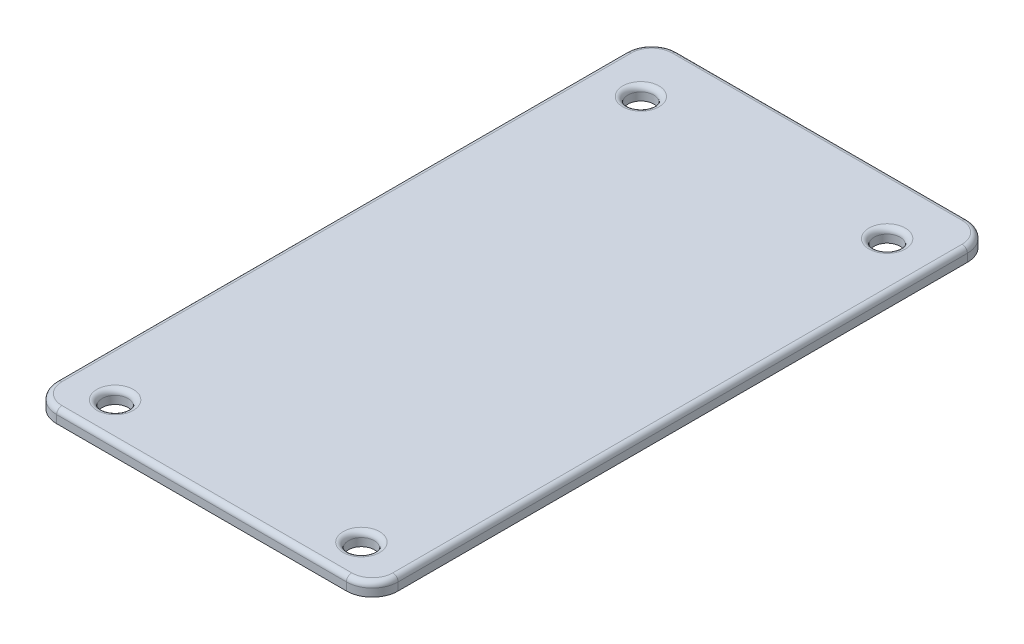
from build123d import *

# Parameters (mm, degrees)
SKETCH1_W           = 33
SKETCH1_H           = 60
BOSS_EXTRUDE1_DEPTH = 1.27
CUT_EXTRUDE1_REACH  = 3.27
SKETCH2_R           = 1.245715159
SKETCH2_R_2         = 1.25
FILLET1_R           = 2.50000008
FILLET2_R           = 0.508


with BuildPart() as part:
    # Sketch1 → Boss-Extrude1 (new body)
    with BuildSketch(Plane(origin=(0, 0, 0), x_dir=(1, 0, 0), z_dir=(0, 1, 0))):
        with Locations((16.989591658, -21.38828823)):
            Rectangle(SKETCH1_W, SKETCH1_H)
    extrude(amount=BOSS_EXTRUDE1_DEPTH)

    # Sketch2 → Cut-Extrude1 (cut, up to next)
    with BuildSketch(Plane(origin=(0, 1.27, 0), x_dir=(1, 0, 0), z_dir=(0, 1, 0)), mode=Mode.PRIVATE) as cut_extrude1_sk1:
        with Locations((5.093876499, 2.96171177)):
            Circle(SKETCH2_R)
    cut_extrude1_tool1 = extrude(cut_extrude1_sk1.sketch, amount=-CUT_EXTRUDE1_REACH, mode=Mode.PRIVATE) & part.part
    add(cut_extrude1_tool1.solids().sort_by_distance((5.093876, 1.27, -2.961712))[0], mode=Mode.SUBTRACT)
    # Sketch2 → Cut-Extrude1 (cut, up to next)
    with BuildSketch(Plane(origin=(0, 1.27, 0), x_dir=(1, 0, 0), z_dir=(0, 1, 0)), mode=Mode.PRIVATE) as cut_extrude1_sk2:
        with Locations((28.889591658, 2.96171177)):
            Circle(SKETCH2_R_2)
    cut_extrude1_tool2 = extrude(cut_extrude1_sk2.sketch, amount=-CUT_EXTRUDE1_REACH, mode=Mode.PRIVATE) & part.part
    add(cut_extrude1_tool2.solids().sort_by_distance((28.889592, 1.27, -2.961712))[0], mode=Mode.SUBTRACT)
    # Sketch2 → Cut-Extrude1 (cut, up to next)
    with BuildSketch(Plane(origin=(0, 1.27, 0), x_dir=(1, 0, 0), z_dir=(0, 1, 0)), mode=Mode.PRIVATE) as cut_extrude1_sk3:
        with Locations((5.089591658, -47.83828823)):
            Circle(SKETCH2_R_2)
    cut_extrude1_tool3 = extrude(cut_extrude1_sk3.sketch, amount=-CUT_EXTRUDE1_REACH, mode=Mode.PRIVATE) & part.part
    add(cut_extrude1_tool3.solids().sort_by_distance((5.089592, 1.27, 47.838288))[0], mode=Mode.SUBTRACT)
    # Sketch2 → Cut-Extrude1 (cut, up to next)
    with BuildSketch(Plane(origin=(0, 1.27, 0), x_dir=(1, 0, 0), z_dir=(0, 1, 0)), mode=Mode.PRIVATE) as cut_extrude1_sk4:
        with Locations((28.889591658, -47.83828823)):
            Circle(SKETCH2_R_2)
    cut_extrude1_tool4 = extrude(cut_extrude1_sk4.sketch, amount=-CUT_EXTRUDE1_REACH, mode=Mode.PRIVATE) & part.part
    add(cut_extrude1_tool4.solids().sort_by_distance((28.889592, 1.27, 47.838288))[0], mode=Mode.SUBTRACT)

    # Fillet1
    fillet1_edges = [part.edges().sort_by_distance(p)[0] for p in [
        (0.489591658, 0.635, -8.61171177),
        (33.489591658, 0.635, -8.61171177),
        (33.489591658, 0.635, 51.38828823),
        (0.489591658, 0.635, 51.38828823),
    ]]
    fillet(fillet1_edges, radius=FILLET1_R)

    # Fillet2
    fillet2_edges = [part.edges().sort_by_distance(p)[0] for p in [
        (27.639591658, 1.27, -2.96171177),
        (3.839591658, 1.27, 47.83828823),
        (27.639591658, 1.27, 47.83828823),
        (3.84816134, 1.27, -2.96171177),
        (33.489591658, 1.27, 21.38828823),
        (16.989591658, 1.27, 51.38828823),
        (0.489591658, 1.27, 21.38828823),
        (16.989591658, 1.27, -8.61171177),
        (32.757358588, 1.27, -7.8794787),
        (1.221824728, 1.27, -7.8794787),
        (1.221824728, 1.27, 50.65605516),
        (32.757358588, 1.27, 50.65605516),
    ]]
    fillet(fillet2_edges, radius=FILLET2_R)


solid = part.part
